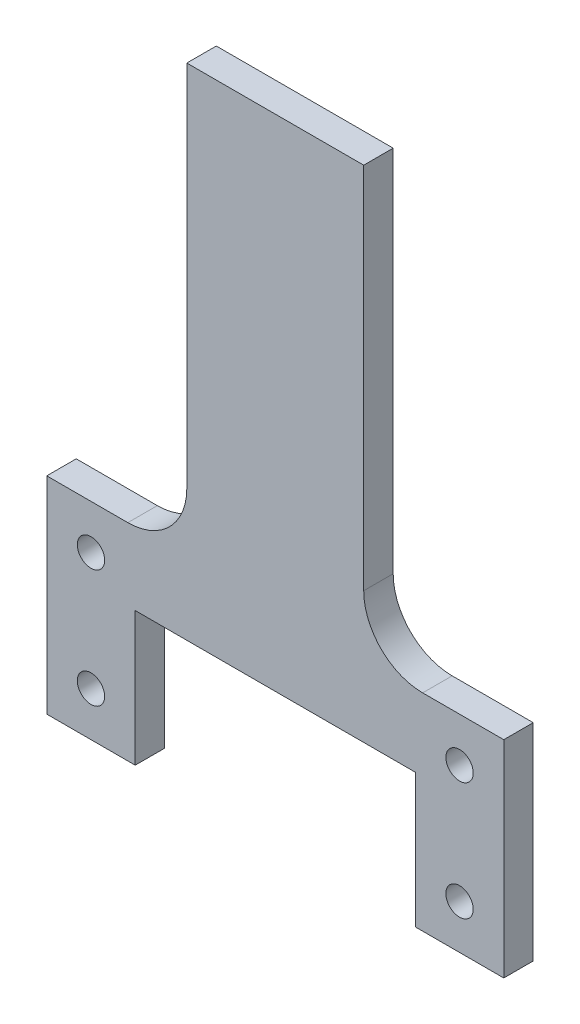
from build123d import *

# Parameters (mm, degrees)
BOSS_EXTRUDE1_DEPTH       = 3.175
F_4_CLEARANCE_HOLE1_D     = 2.9464
F_4_CLEARANCE_HOLE1_DEPTH = 3.302
F_4_CLEARANCE_HOLE1_TIP   = 0.885187864
FILLET1_R                 = 6.35


with BuildPart() as part:
    # Sketch1 → Boss-Extrude1 (new body)
    with BuildSketch(Plane.XY):
        Polygon((-15.08125, -3.0353), (-15.08125, -17.4625), (-24.60625, -17.4625), (-24.60625, 4.7625), (-9.525, 4.7625), (-9.525, 50.8), (9.525, 50.8), (9.525, 4.7625), (24.60625, 4.7625), (24.60625, -17.4625), (15.08125, -17.4625), (15.08125, -3.0353), align=None)
    extrude(amount=BOSS_EXTRUDE1_DEPTH)

    # #4 Clearance Hole1
    with Locations(Plane.XY.offset(3.175)):
        with Locations((-19.84375, 0), (19.84375, 0), (19.84375, -12.7), (-19.84375, -12.7)):
            Hole(F_4_CLEARANCE_HOLE1_D / 2, depth=F_4_CLEARANCE_HOLE1_DEPTH)
            with Locations((0, 0, -(F_4_CLEARANCE_HOLE1_DEPTH + F_4_CLEARANCE_HOLE1_TIP / 2))):  # 118° drill point
                Cone(0, F_4_CLEARANCE_HOLE1_D / 2, F_4_CLEARANCE_HOLE1_TIP, mode=Mode.SUBTRACT)

    # Fillet1
    fillet1_edges = [part.edges().sort_by_distance(p)[0] for p in [
        (-9.525, 4.7625, 1.5875),
        (9.525, 4.7625, 1.5875),
    ]]
    fillet(fillet1_edges, radius=FILLET1_R)


solid = part.part
